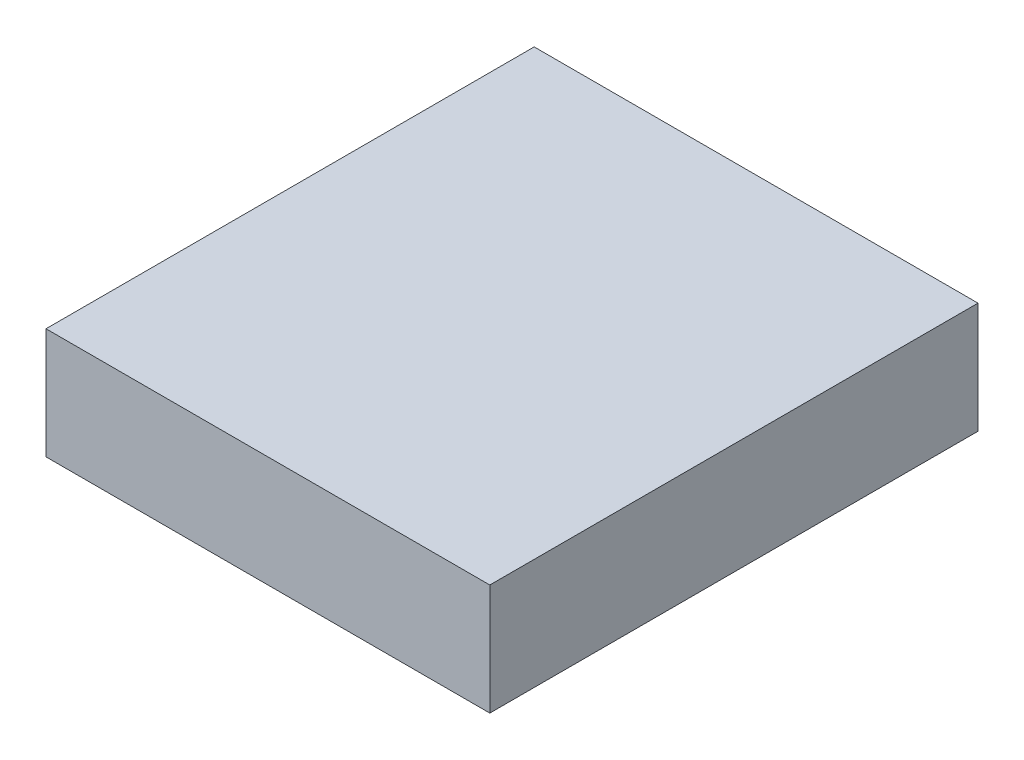
from build123d import *

# Parameters (mm, degrees)
SKETCH1_W            = 200
SKETCH1_H            = 220
BOSS_EXTRUDE1_DEPTH  = 50
BOSS_EXTRUDE20_DEPTH = 3
SKETCH56_R           = 2
CUT_EXTRUDE18_DEPTH  = 4


with BuildPart() as part:
    # Sketch1 → Boss-Extrude1 (new body)
    with BuildSketch(Plane(origin=(0, 0, 0), x_dir=(1, 0, 0), z_dir=(0, 1, 0))):
        Rectangle(SKETCH1_W, SKETCH1_H)
    extrude(amount=BOSS_EXTRUDE1_DEPTH)


with BuildPart() as body_2:
    # Sketch55 → Boss-Extrude20 (new body)
    with BuildSketch(Plane(origin=(0, 0, 0), x_dir=(1, 0, 0), z_dir=(0, 1, 0))):
        with BuildLine():
            Line((55, -15.93788892), (55, -12.5))
            Line((55, -12.5), (55, 12.5))
            Line((55, 12.5), (55, 15.93788892))
            ThreePointArc((55, 15.93788892), (55.055370047, 16.224182781), (55.11165272, 16.510298627))
            ThreePointArc((55.11165272, 16.510298627), (-57.531593289, 0), (55.11165272, -16.510298627))
            ThreePointArc((55.11165272, -16.510298627), (55.055370047, -16.224182781), (55, -15.93788892))
        make_face()
    extrude(amount=BOSS_EXTRUDE20_DEPTH)

    # Sketch56 → Cut-Extrude18 (cut, through all)
    with BuildSketch(Plane(origin=(0, 3, 0), x_dir=(1, 0, 0), z_dir=(0, 1, 0))):
        with Locations(Location((0, 0, 0), (0, 0, 270))):  # turned: the seam where the file's is
            Circle(SKETCH56_R)
        with Locations(Location((0, 49.999999444, 0), (0, 0, 270))):  # turned: the seam where the file's is
            Circle(SKETCH56_R)
        with Locations(Location((0, 39.999999444, 0), (0, 0, 270))):  # turned: the seam where the file's is
            Circle(SKETCH56_R)
        with Locations(Location((0, 29.999999444, 0), (0, 0, 270))):  # turned: the seam where the file's is
            Circle(SKETCH56_R)
        with Locations(Location((0, 19.999999444, 0), (0, 0, 270))):  # turned: the seam where the file's is
            Circle(SKETCH56_R)
        with Locations(Location((0, 9.999999444, 0), (0, 0, 270))):  # turned: the seam where the file's is
            Circle(SKETCH56_R)
        with Locations(Location((10.26060411, 28.190778101, 0), (0, 0, 270))):  # turned: the seam where the file's is
            Circle(SKETCH56_R)
        with Locations(Location((17.320507594, 9.999999722, 0), (0, 0, 270))):  # turned: the seam where the file's is
            Circle(SKETCH56_R)
        with Locations(Location((9.999999722, 17.320507594, 0), (0, 0, 270))):  # turned: the seam where the file's is
            Circle(SKETCH56_R)
        with Locations(Location((-8.660253556, 4.999999722, 0), (0, 0, 270))):  # turned: the seam where the file's is
            Circle(SKETCH56_R)
        with Locations(Location((-8.660253556, -4.999999722, 0), (0, 0, 270))):  # turned: the seam where the file's is
            Circle(SKETCH56_R)
        with Locations(Location((0, -9.999999444, 0), (0, 0, 270))):  # turned: the seam where the file's is
            Circle(SKETCH56_R)
        with Locations(Location((8.660253556, -4.999999722, 0), (0, 0, 270))):  # turned: the seam where the file's is
            Circle(SKETCH56_R)
        with Locations(Location((8.660253556, 4.999999722, 0), (0, 0, 270))):  # turned: the seam where the file's is
            Circle(SKETCH56_R)
        with Locations(Location((-17.320507594, 9.999999722, 0), (0, 0, 270))):  # turned: the seam where the file's is
            Circle(SKETCH56_R)
        with Locations(Location((-19.999999444, 0, 0), (0, 0, 270))):  # turned: the seam where the file's is
            Circle(SKETCH56_R)
        with Locations(Location((-17.320507594, -9.999999722, 0), (0, 0, 270))):  # turned: the seam where the file's is
            Circle(SKETCH56_R)
        with Locations(Location((-9.999999722, -17.320507594, 0), (0, 0, 270))):  # turned: the seam where the file's is
            Circle(SKETCH56_R)
        with Locations(Location((0, -19.999999444, 0), (0, 0, 270))):  # turned: the seam where the file's is
            Circle(SKETCH56_R)
        with Locations(Location((9.999999722, -17.320507594, 0), (0, 0, 270))):  # turned: the seam where the file's is
            Circle(SKETCH56_R)
        with Locations(Location((17.320507594, -9.999999722, 0), (0, 0, 270))):  # turned: the seam where the file's is
            Circle(SKETCH56_R)
        with Locations(Location((19.999999444, 0, 0), (0, 0, 270))):  # turned: the seam where the file's is
            Circle(SKETCH56_R)
        with Locations(Location((10.35276166, 38.637032514, 0), (0, 0, 270))):  # turned: the seam where the file's is
            Circle(SKETCH56_R)
        with Locations(Location((19.283627933, -22.981332867, 0), (0, 0, 270))):  # turned: the seam where the file's is
            Circle(SKETCH56_R)
        with Locations(Location((25.980761632, -14.999999722, 0), (0, 0, 270))):  # turned: the seam where the file's is
            Circle(SKETCH56_R)
        with Locations(Location((29.544232043, -5.209445233, 0), (0, 0, 270))):  # turned: the seam where the file's is
            Circle(SKETCH56_R)
        with Locations(Location((29.544232043, 5.209445233, 0), (0, 0, 270))):  # turned: the seam where the file's is
            Circle(SKETCH56_R)
        with Locations(Location((25.980761632, 14.999999722, 0), (0, 0, 270))):  # turned: the seam where the file's is
            Circle(SKETCH56_R)
        with Locations(Location((19.283627933, 22.981332867, 0), (0, 0, 270))):  # turned: the seam where the file's is
            Circle(SKETCH56_R)
        with Locations(Location((-9.999999722, 17.320507594, 0), (0, 0, 270))):  # turned: the seam where the file's is
            Circle(SKETCH56_R)
        with Locations(Location((-25.980761632, 14.999999722, 0), (0, 0, 270))):  # turned: the seam where the file's is
            Circle(SKETCH56_R)
        with Locations(Location((-29.544232043, 5.209445233, 0), (0, 0, 270))):  # turned: the seam where the file's is
            Circle(SKETCH56_R)
        with Locations(Location((-29.544232043, -5.209445233, 0), (0, 0, 270))):  # turned: the seam where the file's is
            Circle(SKETCH56_R)
        with Locations(Location((-25.980761632, -14.999999722, 0), (0, 0, 270))):  # turned: the seam where the file's is
            Circle(SKETCH56_R)
        with Locations(Location((-19.283627933, -22.981332867, 0), (0, 0, 270))):  # turned: the seam where the file's is
            Circle(SKETCH56_R)
        with Locations(Location((-10.26060411, -28.190778101, 0), (0, 0, 270))):  # turned: the seam where the file's is
            Circle(SKETCH56_R)
        with Locations(Location((0, -29.999999444, 0), (0, 0, 270))):  # turned: the seam where the file's is
            Circle(SKETCH56_R)
        with Locations(Location((10.26060411, -28.190778101, 0), (0, 0, 270))):  # turned: the seam where the file's is
            Circle(SKETCH56_R)
        with Locations(Location((10.395584425, 48.907379493, 0), (0, 0, 270))):  # turned: the seam where the file's is
            Circle(SKETCH56_R)
        with Locations(Location((38.637032514, 10.35276166, 0), (0, 0, 270))):  # turned: the seam where the file's is
            Circle(SKETCH56_R)
        with Locations(Location((34.64101567, 19.999999722, 0), (0, 0, 270))):  # turned: the seam where the file's is
            Circle(SKETCH56_R)
        with Locations(Location((28.284270854, 28.284270854, 0), (0, 0, 270))):  # turned: the seam where the file's is
            Circle(SKETCH56_R)
        with Locations(Location((19.999999722, 34.64101567, 0), (0, 0, 270))):  # turned: the seam where the file's is
            Circle(SKETCH56_R)
        with Locations(Location((-10.26060411, 28.190778101, 0), (0, 0, 270))):  # turned: the seam where the file's is
            Circle(SKETCH56_R)
        with Locations(Location((-19.283627933, 22.981332867, 0), (0, 0, 270))):  # turned: the seam where the file's is
            Circle(SKETCH56_R)
        with Locations(Location((-10.35276166, -38.637032514, 0), (0, 0, 270))):  # turned: the seam where the file's is
            Circle(SKETCH56_R)
        with Locations(Location((0, -39.999999444, 0), (0, 0, 270))):  # turned: the seam where the file's is
            Circle(SKETCH56_R)
        with Locations(Location((10.35276166, -38.637032514, 0), (0, 0, 270))):  # turned: the seam where the file's is
            Circle(SKETCH56_R)
        with Locations(Location((19.999999722, -34.64101567, 0), (0, 0, 270))):  # turned: the seam where the file's is
            Circle(SKETCH56_R)
        with Locations(Location((28.284270854, -28.284270854, 0), (0, 0, 270))):  # turned: the seam where the file's is
            Circle(SKETCH56_R)
        with Locations(Location((34.64101567, -19.999999722, 0), (0, 0, 270))):  # turned: the seam where the file's is
            Circle(SKETCH56_R)
        with Locations(Location((38.637032514, -10.35276166, 0), (0, 0, 270))):  # turned: the seam where the file's is
            Circle(SKETCH56_R)
        with Locations(Location((39.999999444, 0, 0), (0, 0, 270))):  # turned: the seam where the file's is
            Circle(SKETCH56_R)
        with Locations(Location((-28.284270854, 28.284270854, 0), (0, 0, 270))):  # turned: the seam where the file's is
            Circle(SKETCH56_R)
        with Locations(Location((-34.64101567, 19.999999722, 0), (0, 0, 270))):  # turned: the seam where the file's is
            Circle(SKETCH56_R)
        with Locations(Location((-38.637032514, 10.35276166, 0), (0, 0, 270))):  # turned: the seam where the file's is
            Circle(SKETCH56_R)
        with Locations(Location((-39.999999444, 0, 0), (0, 0, 270))):  # turned: the seam where the file's is
            Circle(SKETCH56_R)
        with Locations(Location((-38.637032514, -10.35276166, 0), (0, 0, 270))):  # turned: the seam where the file's is
            Circle(SKETCH56_R)
        with Locations(Location((-34.64101567, -19.999999722, 0), (0, 0, 270))):  # turned: the seam where the file's is
            Circle(SKETCH56_R)
        with Locations(Location((-28.284270854, -28.284270854, 0), (0, 0, 270))):  # turned: the seam where the file's is
            Circle(SKETCH56_R)
        with Locations(Location((-19.999999722, -34.64101567, 0), (0, 0, 270))):  # turned: the seam where the file's is
            Circle(SKETCH56_R)
        with Locations(Location((49.726094215, 5.226423105, 0), (0, 0, 270))):  # turned: the seam where the file's is
            Circle(SKETCH56_R)
        with Locations(Location((47.552825286, 15.450849547, 0), (0, 0, 270))):  # turned: the seam where the file's is
            Circle(SKETCH56_R)
        with Locations(Location((43.301269707, 24.999999722, 0), (0, 0, 270))):  # turned: the seam where the file's is
            Circle(SKETCH56_R)
        with Locations(Location((37.15724086, 33.456529946, 0), (0, 0, 270))):  # turned: the seam where the file's is
            Circle(SKETCH56_R)
        with Locations(Location((29.389262288, 40.450849269, 0), (0, 0, 270))):  # turned: the seam where the file's is
            Circle(SKETCH56_R)
        with Locations(Location((20.336831928, 45.677272374, 0), (0, 0, 270))):  # turned: the seam where the file's is
            Circle(SKETCH56_R)
        with Locations(Location((-19.999999722, 34.64101567, 0), (0, 0, 270))):  # turned: the seam where the file's is
            Circle(SKETCH56_R)
        with Locations(Location((0, -49.999999444, 0), (0, 0, 270))):  # turned: the seam where the file's is
            Circle(SKETCH56_R)
        with Locations(Location((10.395584425, -48.907379493, 0), (0, 0, 270))):  # turned: the seam where the file's is
            Circle(SKETCH56_R)
        with Locations(Location((20.336831928, -45.677272374, 0), (0, 0, 270))):  # turned: the seam where the file's is
            Circle(SKETCH56_R)
        with Locations(Location((29.389262288, -40.450849269, 0), (0, 0, 270))):  # turned: the seam where the file's is
            Circle(SKETCH56_R)
        with Locations(Location((37.15724086, -33.456529946, 0), (0, 0, 270))):  # turned: the seam where the file's is
            Circle(SKETCH56_R)
        with Locations(Location((43.301269707, -24.999999722, 0), (0, 0, 270))):  # turned: the seam where the file's is
            Circle(SKETCH56_R)
        with Locations(Location((47.552825286, -15.450849547, 0), (0, 0, 270))):  # turned: the seam where the file's is
            Circle(SKETCH56_R)
        with Locations(Location((49.726094215, -5.226423105, 0), (0, 0, 270))):  # turned: the seam where the file's is
            Circle(SKETCH56_R)
        with Locations(Location((-49.726094215, 5.226423105, 0), (0, 0, 270))):  # turned: the seam where the file's is
            Circle(SKETCH56_R)
        with Locations(Location((-49.726094215, -5.226423105, 0), (0, 0, 270))):  # turned: the seam where the file's is
            Circle(SKETCH56_R)
        with Locations(Location((-47.552825286, -15.450849547, 0), (0, 0, 270))):  # turned: the seam where the file's is
            Circle(SKETCH56_R)
        with Locations(Location((-43.301269707, -24.999999722, 0), (0, 0, 270))):  # turned: the seam where the file's is
            Circle(SKETCH56_R)
        with Locations(Location((-37.15724086, -33.456529946, 0), (0, 0, 270))):  # turned: the seam where the file's is
            Circle(SKETCH56_R)
        with Locations(Location((-29.389262288, -40.450849269, 0), (0, 0, 270))):  # turned: the seam where the file's is
            Circle(SKETCH56_R)
        with Locations(Location((-20.336831928, -45.677272374, 0), (0, 0, 270))):  # turned: the seam where the file's is
            Circle(SKETCH56_R)
        with Locations(Location((-10.395584425, -48.907379493, 0), (0, 0, 270))):  # turned: the seam where the file's is
            Circle(SKETCH56_R)
        with Locations(Location((-10.35276166, 38.637032514, 0), (0, 0, 270))):  # turned: the seam where the file's is
            Circle(SKETCH56_R)
        with Locations(Location((-10.395584425, 48.907379493, 0), (0, 0, 270))):  # turned: the seam where the file's is
            Circle(SKETCH56_R)
        with Locations(Location((-20.336831928, 45.677272374, 0), (0, 0, 270))):  # turned: the seam where the file's is
            Circle(SKETCH56_R)
        with Locations(Location((-29.389262288, 40.450849269, 0), (0, 0, 270))):  # turned: the seam where the file's is
            Circle(SKETCH56_R)
        with Locations(Location((-37.15724086, 33.456529946, 0), (0, 0, 270))):  # turned: the seam where the file's is
            Circle(SKETCH56_R)
        with Locations(Location((-43.301269707, 24.999999722, 0), (0, 0, 270))):  # turned: the seam where the file's is
            Circle(SKETCH56_R)
        with Locations(Location((-47.552825286, 15.450849547, 0), (0, 0, 270))):  # turned: the seam where the file's is
            Circle(SKETCH56_R)
    extrude(amount=-CUT_EXTRUDE18_DEPTH, mode=Mode.SUBTRACT)


solid = Compound([part.part, body_2.part])
